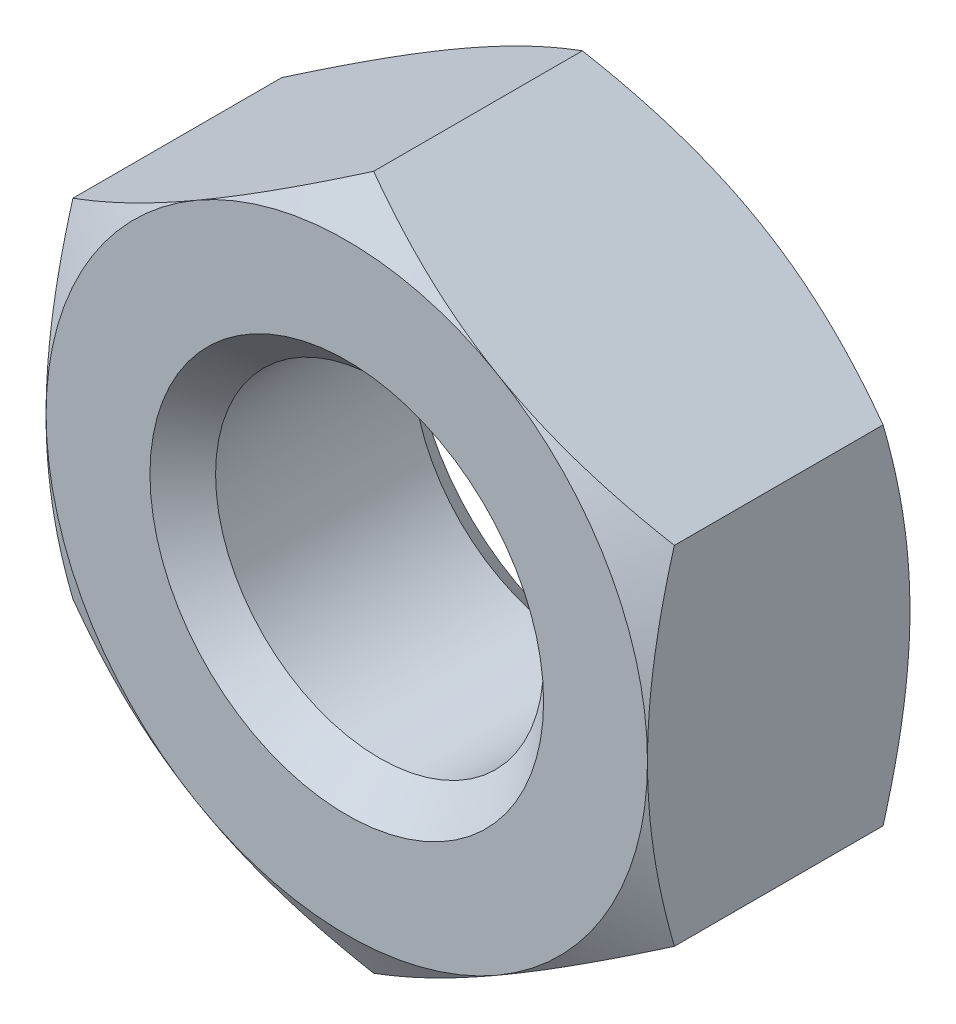
from build123d import *

# Parameters (mm, degrees)
SKETCH1_R           = 3.75
SKETCH1_R_2         = 1.5
BOSS_EXTRUDE1_DEPTH = 2.4
CHAMFER1_SIZE       = 1
CHAMFER1_SIZE2      = 0.577350269
CHAMFER2_SIZE       = 1
CHAMFER2_SIZE2      = 0.577350269
SKETCH1_3_R         = 3.75
CUT_EXTRUDE1_DEPTH  = 6.821082374
CHAMFER3_SIZE       = 0.3


with BuildPart() as part:
    # Sketch1 → Boss-Extrude1 (new body)
    with BuildSketch(Plane.XY):
        Circle(SKETCH1_R)
        Circle(SKETCH1_R_2, mode=Mode.SUBTRACT)
    extrude(amount=BOSS_EXTRUDE1_DEPTH)

    # Chamfer1
    chamfer1_edges = [part.edges().sort_by_distance(p)[0] for p in [
        (-3.75, 0, 2.4),
    ]]
    chamfer1_side = [part.faces().sort_by_distance(p)[0] for p in [
        (-3.643933983, 0, 2.4),
    ]]
    chamfer(chamfer1_edges, length=CHAMFER1_SIZE, length2=CHAMFER1_SIZE2, reference=chamfer1_side[0])

    # Chamfer2
    chamfer2_edges = [part.edges().sort_by_distance(p)[0] for p in [
        (-3.75, 0, 0),
    ]]
    chamfer2_side = [part.faces().sort_by_distance(p)[0] for p in [
        (-3.643933983, 0, 0),
    ]]
    chamfer(chamfer2_edges, length=CHAMFER2_SIZE, length2=CHAMFER2_SIZE2, reference=chamfer2_side[0])

    # Sketch1_3 → Cut-Extrude1 (cut, through all)
    with BuildSketch(Plane.XY):
        Circle(SKETCH1_3_R)
        Polygon((-2.75, 1.58771324), (0, 3.175426481), (2.75, 1.58771324), (2.75, -1.58771324), (0, -3.175426481), (-2.75, -1.58771324), align=None, mode=Mode.SUBTRACT)
    extrude(amount=CUT_EXTRUDE1_DEPTH, mode=Mode.SUBTRACT)

    # Chamfer3
    chamfer3_edges = [part.edges().sort_by_distance(p)[0] for p in [
        (-1.5, 0, 0),
        (-1.5, 0, 2.4),
    ]]
    chamfer(chamfer3_edges, length=CHAMFER3_SIZE)


solid = part.part
